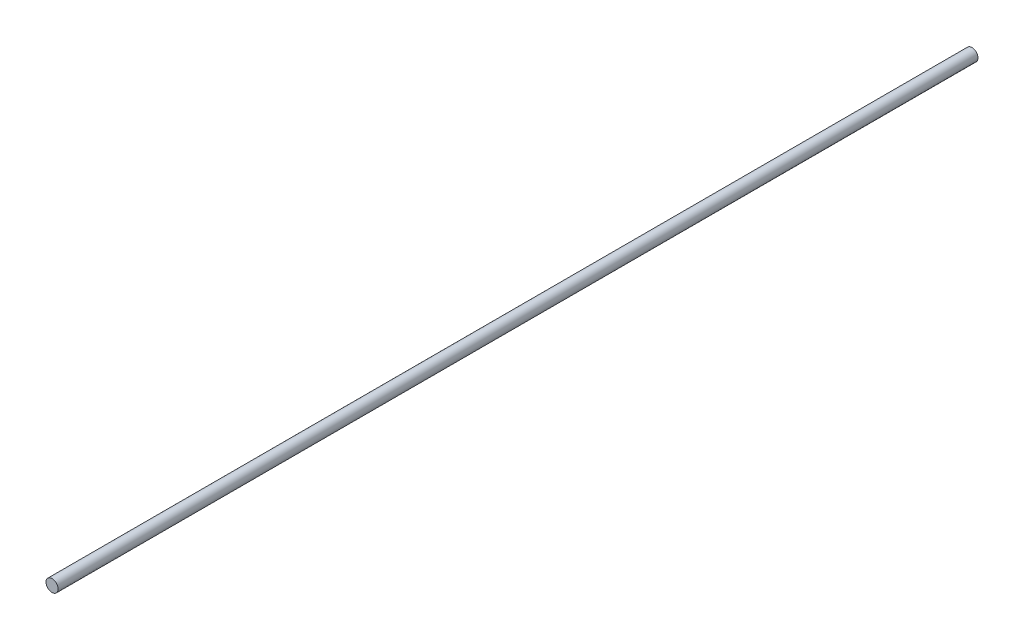
from build123d import *

# Parameters (mm, degrees)
SKETCH1_R           = 3.175
BOSS_EXTRUDE1_DEPTH = 482.6


with BuildPart() as part:
    # Sketch1 → Boss-Extrude1 (new body)
    with BuildSketch(Plane.XY):
        Circle(SKETCH1_R)
    extrude(amount=BOSS_EXTRUDE1_DEPTH)


solid = part.part
